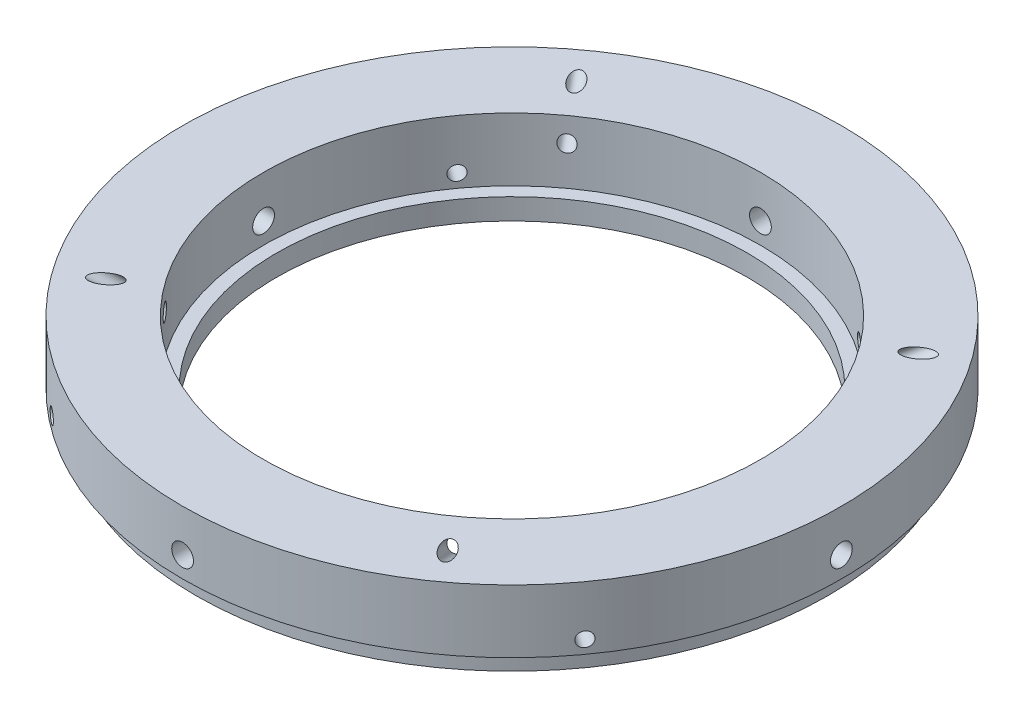
from build123d import *

# Parameters (mm, degrees)
SKETCH5_R          = 1.6425
CUT_EXTRUDE1_DEPTH = 50.7
SKETCH6_R          = 1.095
CUT_EXTRUDE2_DEPTH = 70.421071799
CUT_EXTRUDE3_START = -7.395857
SKETCH7_R          = 1.095
CUT_EXTRUDE3_DEPTH = 9.861143
CIRPATTERN1_COUNT  = 4


with BuildPart() as part:
    # Sketch2 → Revolve1 (revolve)
    with BuildSketch(Plane.XY, mode=Mode.PRIVATE) as revolve1_sk:
        Polygon((49.7, 12.7), (49.7, 3.2004), (47.675, 3.2004), (47.675, 0), (35.5, 0), (35.5, 3.175), (37.5, 3.175), (37.5, 12.7), align=None)
    revolve(revolve1_sk.sketch.rotate(Axis((0, 0, 0), (0, 1, 0)), 90), axis=Axis((0, 0, 0), (0, 1, 0)))  # turned: the seam where the file's is

    # Sketch5 → Cut-Extrude1 (cut, through all)
    with BuildSketch(Plane.XY):
        with Locations(Location((0, 6.35, 0), (0, 0, 270))):  # turned: the seam where the file's is
            Circle(SKETCH5_R)
    cut_extrude1 = extrude(amount=-CUT_EXTRUDE1_DEPTH, mode=Mode.SUBTRACT)

    # Sketch6 → Cut-Extrude2 (cut, through all)
    with BuildSketch(Plane(origin=(0, 0, 0), x_dir=(0.809016994, 0, 0.587785252), z_dir=(-0.587785252, 0, 0.809016994))):
        with Locations((0, 5.175)):
            Circle(SKETCH6_R)
    cut_extrude2 = extrude(amount=-CUT_EXTRUDE2_DEPTH, mode=Mode.SUBTRACT)

    # Sketch7 → Cut-Extrude3 (cut)
    with BuildSketch(Plane(origin=(-19.76384492, 19.412976321, -27.202598826), x_dir=(0.809016994, 0, -0.587785252), z_dir=(0.50903696, -0.5, 0.700629269)).offset(CUT_EXTRUDE3_START)):
        with Locations(Location((0, -10.926477372, 0), (0, 0, 180))):  # turned: the seam where the file's is
            Circle(SKETCH7_R)
    cut_extrude3 = extrude(amount=CUT_EXTRUDE3_DEPTH, mode=Mode.SUBTRACT)

    # CirPattern1: Cut-Extrude1, Cut-Extrude2, Cut-Extrude3 ×4 about axis
    cirpattern1_axis = Axis((0, 13.335, 0), (0, -1, 0))
    add([cut_extrude1.rotate(cirpattern1_axis, i * 360 / CIRPATTERN1_COUNT) for i in range(1, CIRPATTERN1_COUNT)], mode=Mode.SUBTRACT)
    add([cut_extrude2.rotate(cirpattern1_axis, i * 360 / CIRPATTERN1_COUNT) for i in range(1, CIRPATTERN1_COUNT)], mode=Mode.SUBTRACT)
    add([cut_extrude3.rotate(cirpattern1_axis, i * 360 / CIRPATTERN1_COUNT) for i in range(1, CIRPATTERN1_COUNT)], mode=Mode.SUBTRACT)


solid = part.part
